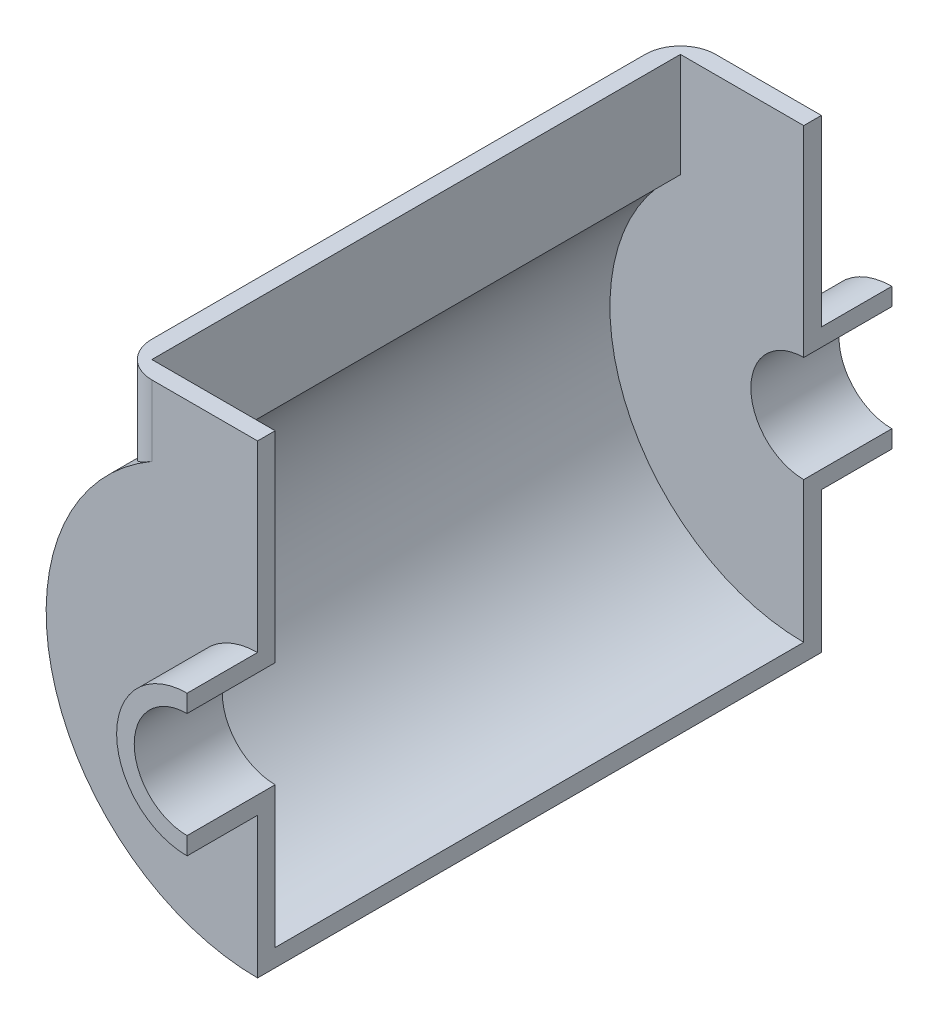
from build123d import *

# Parameters (mm, degrees)
DODANIE_WYCI_GNI_CIE1_DEPTH       = 25
DODANIE_WYCI_GNI_CIE2_DEPTH       = 5
WYCI_GNI_CIE_CIENKA_START         = -150
WYCI_GNI_CIE_CIENKA_CIANKA2_DEPTH = 150
ZAOKR_GLENIE1_R                   = 10


with BuildPart() as part:
    # Szkic1 → Dodanie-wyciągnięcie1 (new body)
    with BuildSketch(Plane.XY):
        with BuildLine():
            Line((0, 20), (0, 15))
            ThreePointArc((0, 15), (-15, 0), (0, -15))
            Line((0, -15), (0, -20))
            ThreePointArc((0, -20), (-20, 0), (0, 20))
        make_face()
    extrude(amount=DODANIE_WYCI_GNI_CIE1_DEPTH)

    # Szkic2 → Dodanie-wyciągnięcie2 (add)
    with BuildSketch(Plane.XY):
        with BuildLine():
            Line((0, -20), (0, -60))
            ThreePointArc((0, -60), (-56.050341538, -21.409325386), (-40, 44.72135955))
            Line((-40, 44.72135955), (-40, 72))
            Line((-40, 72), (0, 72))
            Line((0, 72), (0, 20))
            ThreePointArc((0, 20), (-20, 0), (0, -20))
        make_face()
    extrude(amount=DODANIE_WYCI_GNI_CIE2_DEPTH)


with BuildPart() as body_2:
    # Lustro1: mirrored copy
    add(part.part.mirror(Plane.XY.offset(-75)))


with BuildPart() as part_1:
    add(part.part)

    add(body_2.part)  # Wyciągnięcie-cienka ścianka2 merges body 2
    # Szkic3 → Wyciągnięcie-cienka ścianka2 (add)
    with BuildSketch(Plane.XY.offset(WYCI_GNI_CIE_CIENKA_START)):
        with BuildLine():
            Line((-40, 72), (-40, 44.72135955))
            ThreePointArc((-40, 44.72135955), (-56.050341538, -21.409325386), (0, -60))
            Line((0, -60), (0, -55))
            ThreePointArc((0, -55), (-51.76124215, -18.594994247), (-35, 42.426406871))
            Line((-35, 42.426406871), (-35, 72))
            Line((-35, 72), (-40, 72))
        make_face()
    extrude(amount=WYCI_GNI_CIE_CIENKA_CIANKA2_DEPTH)

    # Zaokrąglenie1
    zaokr_glenie1_edges = [part_1.edges().sort_by_distance(p)[0] for p in [
        (-40, 58.360679775, 5),
        (-40, 58.360679775, -155),
    ]]
    fillet(zaokr_glenie1_edges, radius=ZAOKR_GLENIE1_R)


solid = part_1.part
